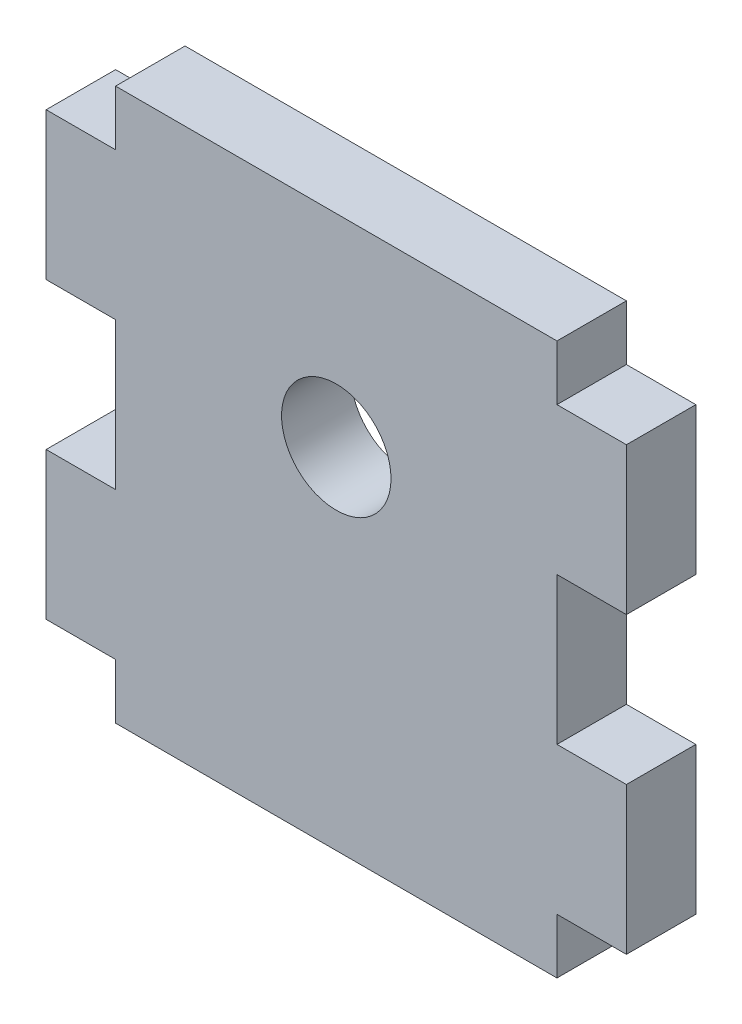
from build123d import *

# Parameters (mm, degrees)
BOSS_EXTRUDE1_DEPTH = 5.9944
SKETCH2_R           = 4.7244
CUT_EXTRUDE1_DEPTH  = 6.9944
SKETCH3_W           = 38.1
SKETCH3_H           = 1.5875
CUT_EXTRUDE2_DEPTH  = 6.9944


with BuildPart() as part:
    # Sketch1 → Boss-Extrude1 (new body)
    with BuildSketch(Plane.XY):
        Polygon((0, 0), (-38.1, 0), (-38.1, 6.35), (-44.0944, 6.35), (-44.0944, 19.05), (-38.1, 19.05), (-38.1, 31.75), (-44.0944, 31.75), (-44.0944, 44.45), (-38.1, 44.45), (-38.1, 50.8), (0, 50.8), (0, 44.45), (5.9944, 44.45), (5.9944, 31.75), (0, 31.75), (0, 19.05), (5.9944, 19.05), (5.9944, 6.35), (0, 6.35), align=None)
    extrude(amount=BOSS_EXTRUDE1_DEPTH)

    # Sketch2 → Cut-Extrude1 (cut, through all)
    with BuildSketch(Plane.XY.offset(5.9944)):
        with Locations((-19.05, 31.75)):
            Circle(SKETCH2_R)
    extrude(amount=-CUT_EXTRUDE1_DEPTH, mode=Mode.SUBTRACT)

    # Sketch3 → Cut-Extrude2 (cut, through all)
    with BuildSketch(Plane.XY.offset(5.9944)):
        with Locations((-19.05, 0.79375)):
            Rectangle(SKETCH3_W, SKETCH3_H)
        with Locations((-19.05, 50.00625)):
            Rectangle(SKETCH3_W, SKETCH3_H)
    extrude(amount=-CUT_EXTRUDE2_DEPTH, mode=Mode.SUBTRACT)


solid = part.part
